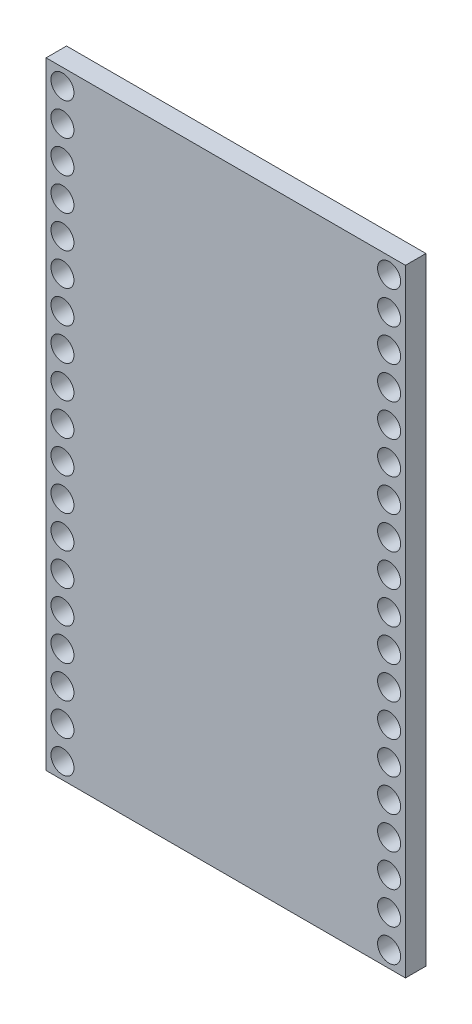
from build123d import *

# Parameters (mm, degrees)
SKETCH_187_W      = 28.1
SKETCH_187_H      = 48.26
SKETCH_187_R      = 0.9
EXTRUDE_851_DEPTH = 1.6


with BuildPart() as part:
    # Sketch 187 → Extrude 851 (new body)
    with BuildSketch(Plane.XY):
        Rectangle(SKETCH_187_W, SKETCH_187_H)
        with Locations((-12.77, 22.85)):
            Circle(SKETCH_187_R, mode=Mode.SUBTRACT)
        with Locations((12.77, 22.85)):
            Circle(SKETCH_187_R, mode=Mode.SUBTRACT)
        with Locations((-12.77, 20.31)):
            Circle(SKETCH_187_R, mode=Mode.SUBTRACT)
        with Locations((12.77, 20.31)):
            Circle(SKETCH_187_R, mode=Mode.SUBTRACT)
        with Locations((-12.77, 17.77)):
            Circle(SKETCH_187_R, mode=Mode.SUBTRACT)
        with Locations((12.77, 17.77)):
            Circle(SKETCH_187_R, mode=Mode.SUBTRACT)
        with Locations((-12.77, 15.23)):
            Circle(SKETCH_187_R, mode=Mode.SUBTRACT)
        with Locations((12.77, 15.23)):
            Circle(SKETCH_187_R, mode=Mode.SUBTRACT)
        with Locations((-12.77, 12.69)):
            Circle(SKETCH_187_R, mode=Mode.SUBTRACT)
        with Locations((12.77, 12.69)):
            Circle(SKETCH_187_R, mode=Mode.SUBTRACT)
        with Locations((-12.77, 10.15)):
            Circle(SKETCH_187_R, mode=Mode.SUBTRACT)
        with Locations((12.77, 10.15)):
            Circle(SKETCH_187_R, mode=Mode.SUBTRACT)
        with Locations((-12.77, 7.61)):
            Circle(SKETCH_187_R, mode=Mode.SUBTRACT)
        with Locations((12.77, 7.61)):
            Circle(SKETCH_187_R, mode=Mode.SUBTRACT)
        with Locations((-12.77, 5.07)):
            Circle(SKETCH_187_R, mode=Mode.SUBTRACT)
        with Locations((12.77, 5.07)):
            Circle(SKETCH_187_R, mode=Mode.SUBTRACT)
        with Locations((-12.77, 2.53)):
            Circle(SKETCH_187_R, mode=Mode.SUBTRACT)
        with Locations((12.77, 2.53)):
            Circle(SKETCH_187_R, mode=Mode.SUBTRACT)
        with Locations((-12.77, -0.01)):
            Circle(SKETCH_187_R, mode=Mode.SUBTRACT)
        with Locations((12.77, -0.01)):
            Circle(SKETCH_187_R, mode=Mode.SUBTRACT)
        with Locations((-12.77, -2.55)):
            Circle(SKETCH_187_R, mode=Mode.SUBTRACT)
        with Locations((12.77, -2.55)):
            Circle(SKETCH_187_R, mode=Mode.SUBTRACT)
        with Locations((-12.77, -5.09)):
            Circle(SKETCH_187_R, mode=Mode.SUBTRACT)
        with Locations((12.77, -5.09)):
            Circle(SKETCH_187_R, mode=Mode.SUBTRACT)
        with Locations((-12.77, -7.63)):
            Circle(SKETCH_187_R, mode=Mode.SUBTRACT)
        with Locations((12.77, -7.63)):
            Circle(SKETCH_187_R, mode=Mode.SUBTRACT)
        with Locations((-12.77, -10.17)):
            Circle(SKETCH_187_R, mode=Mode.SUBTRACT)
        with Locations((12.77, -10.17)):
            Circle(SKETCH_187_R, mode=Mode.SUBTRACT)
        with Locations((-12.77, -12.71)):
            Circle(SKETCH_187_R, mode=Mode.SUBTRACT)
        with Locations((12.77, -12.71)):
            Circle(SKETCH_187_R, mode=Mode.SUBTRACT)
        with Locations((-12.77, -15.25)):
            Circle(SKETCH_187_R, mode=Mode.SUBTRACT)
        with Locations((12.77, -15.25)):
            Circle(SKETCH_187_R, mode=Mode.SUBTRACT)
        with Locations((-12.77, -17.79)):
            Circle(SKETCH_187_R, mode=Mode.SUBTRACT)
        with Locations((12.77, -17.79)):
            Circle(SKETCH_187_R, mode=Mode.SUBTRACT)
        with Locations((-12.77, -20.33)):
            Circle(SKETCH_187_R, mode=Mode.SUBTRACT)
        with Locations((12.77, -20.33)):
            Circle(SKETCH_187_R, mode=Mode.SUBTRACT)
        with Locations((-12.77, -22.87)):
            Circle(SKETCH_187_R, mode=Mode.SUBTRACT)
        with Locations((12.77, -22.87)):
            Circle(SKETCH_187_R, mode=Mode.SUBTRACT)
    extrude(amount=EXTRUDE_851_DEPTH)


solid = part.part
